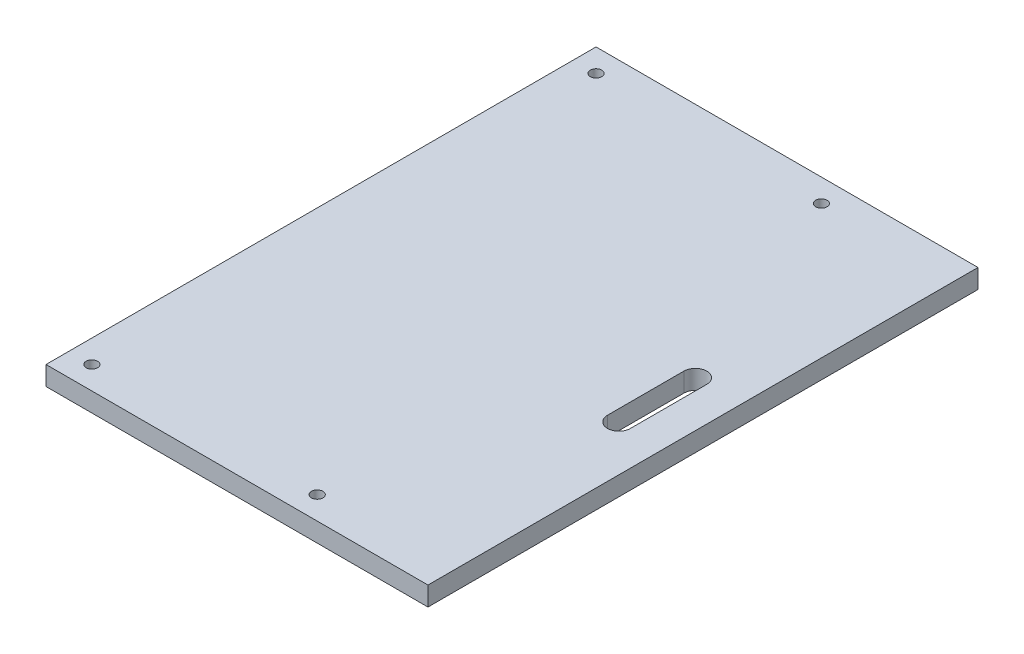
from build123d import *

# Parameters (mm, degrees)
SKETCH1_W           = 100
SKETCH1_H           = 144
BOSS_EXTRUDE1_DEPTH = 5
SKETCH2_R           = 1.5
CUT_EXTRUDE1_DEPTH  = 6


with BuildPart() as part:
    # Sketch1 → Boss-Extrude1 (new body)
    with BuildSketch(Plane(origin=(0, 0, 0), x_dir=(1, 0, 0), z_dir=(0, 1, 0))):
        with Locations((50, 72)):
            Rectangle(SKETCH1_W, SKETCH1_H)
        with BuildLine():
            Line((85, 82), (85, 62))
            ThreePointArc((85, 62), (88, 59), (91, 62))
            Line((91, 62), (91, 82))
            ThreePointArc((91, 82), (88, 85), (85, 82))
        make_face(mode=Mode.SUBTRACT)
    extrude(amount=BOSS_EXTRUDE1_DEPTH)

    # Sketch2 → Cut-Extrude1 (cut, through all)
    with BuildSketch(Plane(origin=(0, 5, 0), x_dir=(1, 0, 0), z_dir=(0, 1, 0))):
        with Locations((6, 138)):
            Circle(SKETCH2_R)
        with Locations((6, 6)):
            Circle(SKETCH2_R)
        with Locations((65, 138)):
            Circle(SKETCH2_R)
        with Locations((65, 6)):
            Circle(SKETCH2_R)
    extrude(amount=-CUT_EXTRUDE1_DEPTH, mode=Mode.SUBTRACT)


solid = part.part
